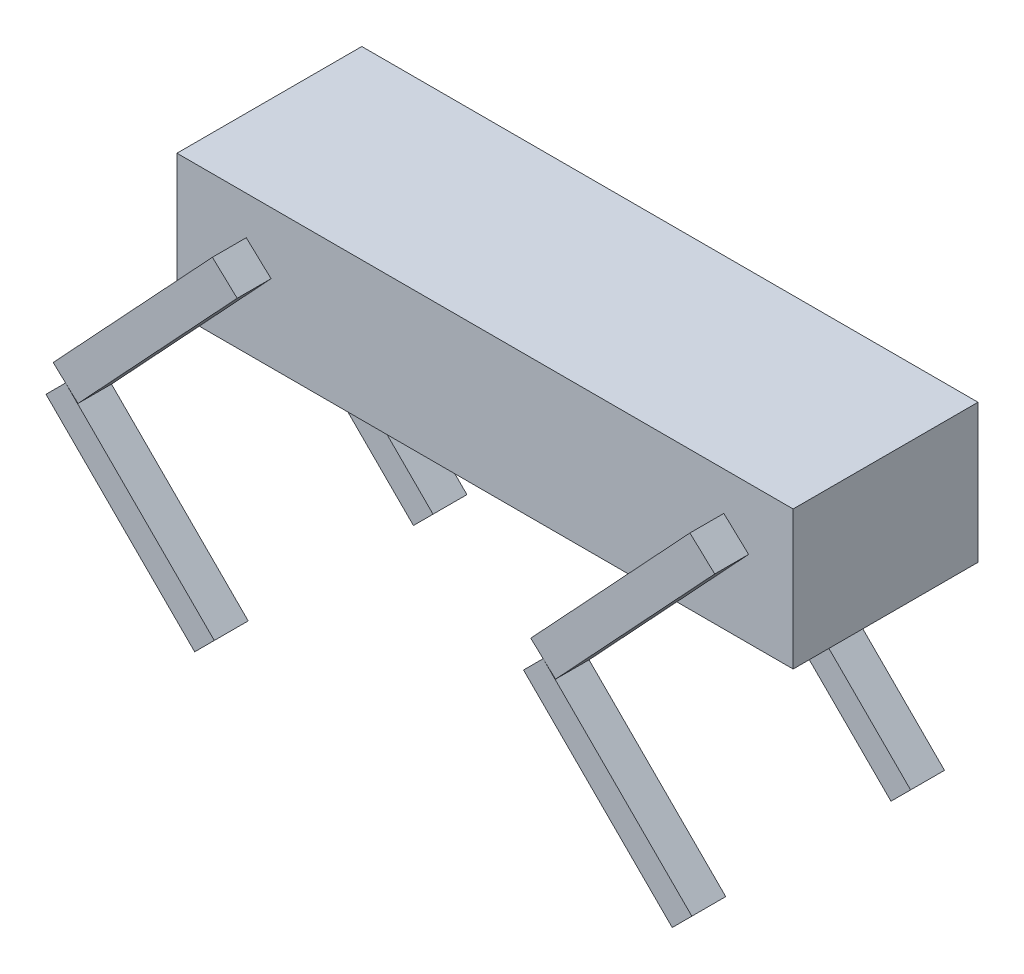
from build123d import *

# Parameters (mm, degrees)
SKETCH1_W             = 400
SKETCH1_H             = 90
BOSS_EXTRUDE1_DEPTH   = 120
BOSS_EXTRUDE2_DEPTH   = 22
BOSS_EXTRUDE2_2_DEPTH = 22
BOSS_EXTRUDE2_3_DEPTH = 22
BOSS_EXTRUDE2_4_DEPTH = 22
BOSS_EXTRUDE3_START   = -120
BOSS_EXTRUDE3_DEPTH   = 22


with BuildPart() as part:
    # Sketch1 → Boss-Extrude1 (new body)
    with BuildSketch(Plane.XY):
        Rectangle(SKETCH1_W, SKETCH1_H)
    extrude(amount=BOSS_EXTRUDE1_DEPTH)

    # Sketch2_3 → Boss-Extrude3 (add)
    with BuildSketch(Plane.XY.offset(120).offset(BOSS_EXTRUDE3_START)):
        Polygon((-155, 20), (-258.322751549, -90.800085795), (-242.232970114, -105.804049717), (-138.910218564, 4.996036079), align=None)
        Polygon((155, 20), (51.677248451, -90.800085795), (67.767029886, -105.804049717), (171.089781436, 4.996036079), align=None)
        Polygon((-250.277860832, -98.302067756), (-153.7577852, -194.822143388), (-166.485707261, -207.550065449), (-263.005782893, -111.029989817), align=None)
        Polygon((59.722139168, -98.302067756), (156.2422148, -194.822143388), (143.514292739, -207.550065449), (46.994217107, -111.029989817), align=None)
    extrude(amount=-BOSS_EXTRUDE3_DEPTH)


with BuildPart() as body_2:
    # Sketch2 → Boss-Extrude2 (new body)
    with BuildSketch(Plane.XY.offset(120)):
        Polygon((-155, 20), (-258.322751549, -90.800085795), (-242.232970114, -105.804049717), (-138.910218564, 4.996036079), align=None)
    extrude(amount=BOSS_EXTRUDE2_DEPTH)


with BuildPart() as body_3:
    # Sketch2 → Boss-Extrude2 2 (new body)
    with BuildSketch(Plane.XY.offset(120)):
        Polygon((155, 20), (51.677248451, -90.800085795), (67.767029886, -105.804049717), (171.089781436, 4.996036079), align=None)
    extrude(amount=BOSS_EXTRUDE2_2_DEPTH)


with BuildPart() as body_4:
    # Sketch2 → Boss-Extrude2 3 (new body)
    with BuildSketch(Plane.XY.offset(120)):
        Polygon((-250.277860832, -98.302067756), (-153.7577852, -194.822143388), (-166.485707261, -207.550065449), (-263.005782893, -111.029989817), align=None)
    extrude(amount=BOSS_EXTRUDE2_3_DEPTH)


with BuildPart() as body_5:
    # Sketch2 → Boss-Extrude2 4 (new body)
    with BuildSketch(Plane.XY.offset(120)):
        Polygon((59.722139168, -98.302067756), (156.2422148, -194.822143388), (143.514292739, -207.550065449), (46.994217107, -111.029989817), align=None)
    extrude(amount=BOSS_EXTRUDE2_4_DEPTH)


solid = Compound([part.part, body_2.part, body_3.part, body_4.part, body_5.part])
